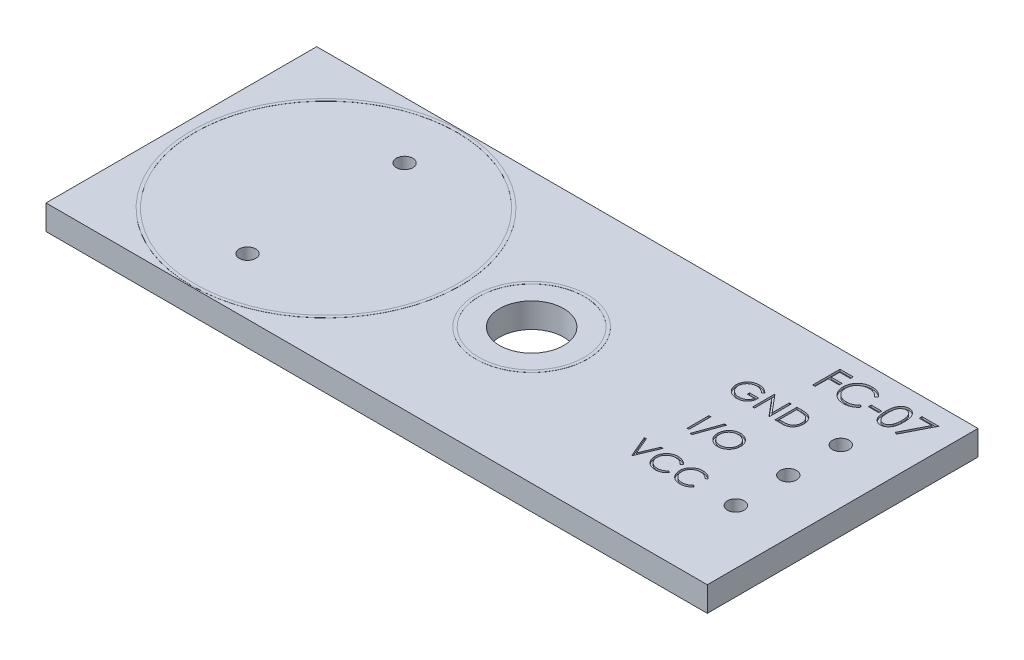
from build123d import *

# Parameters (mm, degrees)
SKETCH1_W           = 32
SKETCH1_H           = 13.1
BOSS_EXTRUDE1_DEPTH = 1.2
CUT_EXTRUDE1_REACH  = 3.2
SKETCH2_R           = 1.55
CUT_EXTRUDE2_REACH  = 3.2
SKETCH4_R           = 0.4
CUT_EXTRUDE3_REACH  = 3.2
SKETCH5_R           = 0.4
SKETCH6_W           = 0.094978632
SKETCH6_H           = 1.058333333
CUT_EXTRUDE4_DEPTH  = 0.1
SKETCH7_W           = 0.508814102
SKETCH7_H           = 0.13568376
CUT_EXTRUDE5_DEPTH  = 0.1
SKETCH8_R           = 6.5
SKETCH8_R_2         = 6.35
SKETCH8_R_3         = 2.7
SKETCH8_R_4         = 2.55
BOSS_EXTRUDE2_DEPTH = 0.005


with BuildPart() as part:
    # Sketch1 → Boss-Extrude1 (new body)
    with BuildSketch(Plane(origin=(0, 0, 0), x_dir=(1, 0, 0), z_dir=(0, 1, 0))):
        Rectangle(SKETCH1_W, SKETCH1_H)
    extrude(amount=BOSS_EXTRUDE1_DEPTH)

    # Sketch2 → Cut-Extrude1 (cut, up to next)
    with BuildSketch(Plane(origin=(0, 1.2, 0), x_dir=(1, 0, 0), z_dir=(0, 1, 0)), mode=Mode.PRIVATE) as cut_extrude1_sk1:
        with Locations((0.95, 0)):
            Circle(SKETCH2_R)
    cut_extrude1_tool1 = extrude(cut_extrude1_sk1.sketch, amount=-CUT_EXTRUDE1_REACH, mode=Mode.PRIVATE) & part.part
    add(cut_extrude1_tool1.solids().sort_by_distance((0.95, 1.2, 0))[0], mode=Mode.SUBTRACT)

    # Sketch4 → Cut-Extrude2 (cut, up to next)
    with BuildSketch(Plane(origin=(0, 1.2, 0), x_dir=(1, 0, 0), z_dir=(0, 1, 0)), mode=Mode.PRIVATE) as cut_extrude2_sk1:
        with Locations((13.37, 0)):
            Circle(SKETCH4_R)
    cut_extrude2_tool1 = extrude(cut_extrude2_sk1.sketch, amount=-CUT_EXTRUDE2_REACH, mode=Mode.PRIVATE) & part.part
    add(cut_extrude2_tool1.solids().sort_by_distance((13.37, 1.2, 0))[0], mode=Mode.SUBTRACT)
    # Sketch4 → Cut-Extrude2 (cut, up to next)
    with BuildSketch(Plane(origin=(0, 1.2, 0), x_dir=(1, 0, 0), z_dir=(0, 1, 0)), mode=Mode.PRIVATE) as cut_extrude2_sk2:
        with Locations((13.37, 2.54)):
            Circle(SKETCH4_R)
    cut_extrude2_tool2 = extrude(cut_extrude2_sk2.sketch, amount=-CUT_EXTRUDE2_REACH, mode=Mode.PRIVATE) & part.part
    add(cut_extrude2_tool2.solids().sort_by_distance((13.37, 1.2, -2.54))[0], mode=Mode.SUBTRACT)
    # Sketch4 → Cut-Extrude2 (cut, up to next)
    with BuildSketch(Plane(origin=(0, 1.2, 0), x_dir=(1, 0, 0), z_dir=(0, 1, 0)), mode=Mode.PRIVATE) as cut_extrude2_sk3:
        with Locations((13.37, -2.54)):
            Circle(SKETCH4_R)
    cut_extrude2_tool3 = extrude(cut_extrude2_sk3.sketch, amount=-CUT_EXTRUDE2_REACH, mode=Mode.PRIVATE) & part.part
    add(cut_extrude2_tool3.solids().sort_by_distance((13.37, 1.2, 2.54))[0], mode=Mode.SUBTRACT)

    # Sketch5 → Cut-Extrude3 (cut, up to next)
    with BuildSketch(Plane(origin=(0, 1.2, 0), x_dir=(1, 0, 0), z_dir=(0, 1, 0)), mode=Mode.PRIVATE) as cut_extrude3_sk1:
        with Locations((-9, -3.8)):
            Circle(SKETCH5_R)
    cut_extrude3_tool1 = extrude(cut_extrude3_sk1.sketch, amount=-CUT_EXTRUDE3_REACH, mode=Mode.PRIVATE) & part.part
    add(cut_extrude3_tool1.solids().sort_by_distance((-9, 1.2, 3.8))[0], mode=Mode.SUBTRACT)
    # Sketch5 → Cut-Extrude3 (cut, up to next)
    with BuildSketch(Plane(origin=(0, 1.2, 0), x_dir=(1, 0, 0), z_dir=(0, 1, 0)), mode=Mode.PRIVATE) as cut_extrude3_sk2:
        with Locations((-9, 3.8)):
            Circle(SKETCH5_R)
    cut_extrude3_tool2 = extrude(cut_extrude3_sk2.sketch, amount=-CUT_EXTRUDE3_REACH, mode=Mode.PRIVATE) & part.part
    add(cut_extrude3_tool2.solids().sort_by_distance((-9, 1.2, -3.8))[0], mode=Mode.SUBTRACT)

    # Sketch6 → Cut-Extrude4 (cut)
    with BuildSketch(Plane(origin=(0, 1.2, 0), x_dir=(1, 0, 0), z_dir=(0, 1, 0))):
        with BuildLine():
            Line((9.359822658, 2.876299306), (9.278412401, 2.799129167))
            add(Edge.make_bspline(
                [(9.278412401, 2.799129167), (9.263680738, 2.812987547), (9.234568695, 2.840373846), (9.187106907, 2.875906933), (9.137587904, 2.906346444), (9.086270077, 2.93111333), (9.034424276, 2.95087476), (8.98273867, 2.964943983), (8.931743422, 2.973916393), (8.897826192, 2.974989353), (8.88111339, 2.975518056)],
                knots=[0, 0, 0, 0, 6.0638e-05, 0.00011983, 0.000177497, 0.000234768, 0.000290524, 0.000343703, 0.000395286, 0.000445395, 0.000445395, 0.000445395, 0.000445395], degree=3))
            add(Edge.make_bspline(
                [(8.88111339, 2.975518056), (8.87085823, 2.97539299), (8.850374509, 2.975143181), (8.81994835, 2.971954811), (8.789841295, 2.967369245), (8.760110179, 2.960734439), (8.730697195, 2.952325509), (8.70170464, 2.941807048), (8.67307843, 2.929543914), (8.64508821, 2.915373595), (8.617952391, 2.89980707), (8.592323539, 2.882556678), (8.568038297, 2.864175306), (8.54555312, 2.844202748), (8.524738671, 2.822819919), (8.505099521, 2.800424586), (8.487326386, 2.776404889), (8.471272629, 2.751202759), (8.456951378, 2.725260835), (8.444309237, 2.698828812), (8.433696546, 2.671994361), (8.425299592, 2.644723809), (8.418371847, 2.617228131), (8.413498189, 2.589316941), (8.410750537, 2.560960356), (8.410275261, 2.541971661), (8.410036333, 2.532425775)],
                knots=[0, 0, 0, 0, 3.0753e-05, 6.1425e-05, 9.168e-05, 0.00012208, 0.000152744, 0.000183391, 0.000214542, 0.000246114, 0.00027746, 0.00030833, 0.000338732, 0.000368769, 0.000398452, 0.000428209, 0.000458059, 0.000487994, 0.000517791, 0.000546904, 0.00057584, 0.000604271, 0.000632449, 0.000660855, 0.000689186, 0.000717826, 0.000717826, 0.000717826, 0.000717826], degree=3))
            add(Edge.make_bspline(
                [(8.410036333, 2.532425775), (8.410264848, 2.522667695), (8.410721253, 2.50317818), (8.41364235, 2.474090925), (8.419063508, 2.445435672), (8.426310887, 2.41711826), (8.435376515, 2.389090192), (8.446677297, 2.361472981), (8.460062371, 2.334267649), (8.475555329, 2.307719321), (8.492544967, 2.281858788), (8.511577755, 2.257499123), (8.531795122, 2.234315945), (8.553933611, 2.212823988), (8.57728333, 2.192448382), (8.602541899, 2.173750498), (8.629212643, 2.156370178), (8.657336252, 2.140526468), (8.68660757, 2.126372459), (8.716620921, 2.113786185), (8.747472189, 2.103420767), (8.778999241, 2.094972816), (8.811164492, 2.088048202), (8.844131213, 2.083593381), (8.877657008, 2.080360677), (8.900256547, 2.080124315), (8.911642236, 2.080005236)],
                knots=[0, 0, 0, 0, 2.9276e-05, 5.8472e-05, 8.7579e-05, 0.000116683, 0.000146115, 0.000175878, 0.000206124, 0.000236996, 0.000268043, 0.000298872, 0.000329665, 0.000360248, 0.000391361, 0.000422569, 0.00045444, 0.000486811, 0.000519334, 0.000551934, 0.000584383, 0.000616885, 0.000649817, 0.000683007, 0.000716635, 0.000750778, 0.000750778, 0.000750778, 0.000750778], degree=3))
            add(Edge.make_bspline(
                [(8.911642236, 2.080005236), (8.925363784, 2.080292067), (8.952308272, 2.080855307), (8.991916077, 2.085239918), (9.02995653, 2.092087877), (9.066322739, 2.102116613), (9.101056943, 2.114908438), (9.134286475, 2.130328472), (9.165749715, 2.148968159), (9.195541246, 2.170005971), (9.22298449, 2.19344498), (9.247735618, 2.21873747), (9.269399849, 2.245760671), (9.28830008, 2.274355421), (9.303935792, 2.304758406), (9.316769685, 2.336820633), (9.326607132, 2.370556524), (9.330645422, 2.393867565), (9.332685906, 2.405646261)],
                knots=[0, 0, 0, 0, 4.1156e-05, 8.0816e-05, 0.000119405, 0.000157002, 0.000193826, 0.000230341, 0.000266738, 0.000303385, 0.000339626, 0.000374858, 0.000409391, 0.000443378, 0.000477514, 0.000511764, 0.000546856, 0.000582697, 0.000582697, 0.000582697, 0.000582697], degree=3))
            Line((9.332685906, 2.405646261), (8.979908128, 2.405646261))
            Line((8.979908128, 2.405646261), (8.979908128, 2.51419327))
            Line((8.979908128, 2.51419327), (9.427664538, 2.51419327))
            add(Edge.make_bspline(
                [(9.427664538, 2.51419327), (9.427148722, 2.49396172), (9.426139177, 2.454364921), (9.419057743, 2.396619149), (9.40762275, 2.342078184), (9.392001655, 2.290684589), (9.371779845, 2.242511193), (9.347174342, 2.197509086), (9.317791343, 2.155968994), (9.284677472, 2.117551796), (9.247514866, 2.0832832), (9.207307688, 2.053164262), (9.163989509, 2.027793709), (9.117601305, 2.007152985), (9.068294936, 1.991043944), (9.015956307, 1.979622539), (8.960656394, 1.972779669), (8.922756971, 1.971905371), (8.903374007, 1.971458227)],
                knots=[0, 0, 0, 0, 6.0687e-05, 0.000118775, 0.000174243, 0.000227691, 0.000279665, 0.000330713, 0.000381237, 0.000432035, 0.000482592, 0.000532583, 0.00058247, 0.000632862, 0.00068462, 0.000737808, 0.000793345, 0.000851482, 0.000851482, 0.000851482, 0.000851482], degree=3))
            add(Edge.make_bspline(
                [(8.903374007, 1.971458227), (8.891426894, 1.971630318), (8.867863338, 1.971969738), (8.833062034, 1.974381936), (8.799220277, 1.978095348), (8.766342998, 1.983703041), (8.734309261, 1.990571519), (8.703279053, 1.999366789), (8.67313417, 2.009547562), (8.643828017, 2.021127445), (8.615626594, 2.034544588), (8.58840429, 2.049454884), (8.562010629, 2.065781448), (8.536625395, 2.083806632), (8.512116324, 2.103395614), (8.488641449, 2.124587656), (8.466069353, 2.147317971), (8.451929879, 2.163458767), (8.444805297, 2.171591774)],
                knots=[0, 0, 0, 0, 3.5839e-05, 7.0686e-05, 0.00010461, 0.00013793, 0.000170699, 0.000202849, 0.000234627, 0.000266122, 0.000297322, 0.000328252, 0.000359197, 0.000390373, 0.000421596, 0.00045327, 0.000485201, 0.000517632, 0.000517632, 0.000517632, 0.000517632], degree=3))
            add(Edge.make_bspline(
                [(8.444805297, 2.171591774), (8.434468122, 2.184494567), (8.413965359, 2.210085979), (8.387574107, 2.251088819), (8.36507654, 2.293543668), (8.34682246, 2.33756871), (8.332568801, 2.383122767), (8.322346434, 2.430147629), (8.316357087, 2.478703851), (8.315494232, 2.511562157), (8.3150577, 2.528185658)],
                knots=[0, 0, 0, 0, 4.9572e-05, 9.8322e-05, 0.000146023, 0.000193545, 0.000241086, 0.000289032, 0.000337732, 0.000387599, 0.000387599, 0.000387599, 0.000387599], degree=3))
            add(Edge.make_bspline(
                [(8.3150577, 2.528185658), (8.315218639, 2.540633548), (8.315538471, 2.565371125), (8.319416663, 2.602097501), (8.324980901, 2.638171758), (8.333159415, 2.673564407), (8.343469476, 2.708299086), (8.35633684, 2.742391923), (8.371318273, 2.775863036), (8.38873103, 2.808482039), (8.40810895, 2.839816088), (8.429139612, 2.869739043), (8.452121653, 2.897705974), (8.476679763, 2.924071068), (8.503106949, 2.9485031), (8.531155631, 2.971228272), (8.560847428, 2.992277066), (8.592275749, 3.011317944), (8.624971501, 3.028421706), (8.658856311, 3.043416539), (8.693919835, 3.055809113), (8.729899382, 3.066324042), (8.767067293, 3.07409981), (8.805153848, 3.079738836), (8.844357573, 3.083597398), (8.870857039, 3.083907718), (8.884293478, 3.084065065)],
                knots=[0, 0, 0, 0, 3.7328e-05, 7.4182e-05, 0.000110674, 0.000146778, 0.000183065, 0.000219293, 0.000256017, 0.000293005, 0.000330131, 0.000366483, 0.000402641, 0.000438639, 0.000474493, 0.000510518, 0.00054687, 0.000583593, 0.00062067, 0.000657501, 0.000694651, 0.000732159, 0.000769873, 0.000808461, 0.000847636, 0.000887931, 0.000887931, 0.000887931, 0.000887931], degree=3))
            add(Edge.make_bspline(
                [(8.884293478, 3.084065065), (8.895251232, 3.083889837), (8.916979172, 3.083542382), (8.949311477, 3.081134024), (8.981144031, 3.077316803), (9.012524035, 3.072107751), (9.043344627, 3.065012778), (9.073693607, 3.05652244), (9.103614969, 3.046637055), (9.133014939, 3.034847571), (9.162091201, 3.021466117), (9.191005424, 3.006403487), (9.219658815, 2.989402117), (9.248101064, 2.970411524), (9.276511526, 2.949757871), (9.304440835, 2.926850451), (9.332563154, 2.902592618), (9.350646083, 2.885150624), (9.359822658, 2.876299306)],
                knots=[0, 0, 0, 0, 3.2872e-05, 6.5181e-05, 9.721e-05, 0.000129031, 0.000160558, 0.000192039, 0.000223549, 0.000255044, 0.000287012, 0.000319538, 0.000352806, 0.00038691, 0.000422106, 0.00045813, 0.000495246, 0.000533487, 0.000533487, 0.000533487, 0.000533487], degree=3))
        make_face()
        Polygon((9.644758555, 1.998594979), (9.644758555, 3.056928312), (9.664687108, 3.056928312), (10.363882487, 2.223957225), (10.363882487, 3.056928312), (10.458861119, 3.056928312), (10.458861119, 1.998594979), (10.43723652, 1.998594979), (9.739737188, 2.829658013), (9.739737188, 1.998594979), align=None)
        with BuildLine():
            Line((10.730228641, 1.998594979), (10.730228641, 3.056928312))
            Line((10.730228641, 3.056928312), (10.943930564, 3.056928312))
            add(Edge.make_bspline(
                [(10.943930564, 3.056928312), (10.962517615, 3.056794488), (10.998427701, 3.056535939), (11.050320036, 3.054896614), (11.098333222, 3.051996639), (11.142309348, 3.047772521), (11.182369143, 3.04258577), (11.218400437, 3.036084457), (11.250589537, 3.028407558), (11.270386249, 3.021862386), (11.279747871, 3.018767255)],
                knots=[0, 0, 0, 0, 5.5761e-05, 0.00010773, 0.000155735, 0.000200036, 0.000240244, 0.000276879, 0.000309839, 0.000339409, 0.000339409, 0.000339409, 0.000339409], degree=3))
            add(Edge.make_bspline(
                [(11.279747871, 3.018767255), (11.291992709, 3.014101303), (11.316204713, 3.004875209), (11.350678295, 2.987471279), (11.38313144, 2.96775208), (11.413738182, 2.945691616), (11.441799384, 2.920665254), (11.468411296, 2.893736088), (11.492485272, 2.863924851), (11.514531352, 2.831849795), (11.534408563, 2.79788877), (11.551686356, 2.762106487), (11.56603554, 2.724684665), (11.577947301, 2.68572737), (11.587335158, 2.645148942), (11.593740171, 2.60290213), (11.597964732, 2.559153899), (11.598389291, 2.529467811), (11.598604709, 2.514405276)],
                knots=[0, 0, 0, 0, 3.929e-05, 7.7689e-05, 0.000115648, 0.000153134, 0.000190689, 0.000228319, 0.000266595, 0.000305467, 0.000344991, 0.000384532, 0.000424533, 0.000465106, 0.00050666, 0.000549358, 0.000593216, 0.000638392, 0.000638392, 0.000638392, 0.000638392], degree=3))
            add(Edge.make_bspline(
                [(11.598604709, 2.514405276), (11.598414521, 2.501323901), (11.598039736, 2.475545686), (11.594674443, 2.437554273), (11.589783032, 2.400689931), (11.582210144, 2.365128207), (11.573017003, 2.330557532), (11.561234986, 2.297346353), (11.547738062, 2.265190011), (11.53199917, 2.234523298), (11.514720703, 2.205469516), (11.496178176, 2.178081202), (11.476391366, 2.15274917), (11.455171591, 2.129396709), (11.432793068, 2.108059022), (11.409109282, 2.088557865), (11.384059121, 2.071274812), (11.357754784, 2.05553071), (11.329428907, 2.04179646), (11.298544966, 2.030175957), (11.264971253, 2.020546147), (11.228790175, 2.012511614), (11.189939219, 2.006138239), (11.148380294, 2.001866687), (11.104177251, 1.998978062), (11.073824473, 1.998725153), (11.058201731, 1.998594979)],
                knots=[0, 0, 0, 0, 3.9235e-05, 7.7317e-05, 0.000114346, 0.000150727, 0.000186317, 0.000221585, 0.000256355, 0.000290867, 0.000324899, 0.000357711, 0.000390028, 0.000421245, 0.000452286, 0.000482716, 0.00051318, 0.000543503, 0.000574604, 0.000607482, 0.00064237, 0.0006793, 0.000718615, 0.000760406, 0.000804589, 0.00085145, 0.00085145, 0.00085145, 0.00085145], degree=3))
            Line((11.058201731, 1.998594979), (10.730228641, 1.998594979))
        make_face()
        with BuildLine():
            Line((10.825207273, 2.107141988), (10.94668664, 2.107141988))
            add(Edge.make_bspline(
                [(10.94668664, 2.107141988), (10.9641426, 2.107217007), (10.997716803, 2.107361297), (11.04599434, 2.108627428), (11.090105491, 2.1106963), (11.130056519, 2.113591621), (11.165824867, 2.117422369), (11.197485287, 2.12169347), (11.224933996, 2.127014604), (11.241543611, 2.13183787), (11.249219025, 2.134066734)],
                knots=[0, 0, 0, 0, 5.2367e-05, 0.000100721, 0.000144869, 0.000184837, 0.000220869, 0.00025277, 0.000280668, 0.000304636, 0.000304636, 0.000304636, 0.000304636], degree=3))
            add(Edge.make_bspline(
                [(11.249219025, 2.134066734), (11.258879601, 2.137468991), (11.277970011, 2.144192242), (11.30545072, 2.156456106), (11.331079624, 2.170983113), (11.35530337, 2.187130943), (11.377778335, 2.205469139), (11.398770865, 2.225598938), (11.418238695, 2.247622787), (11.435980688, 2.27151335), (11.451858199, 2.297121931), (11.465607833, 2.324196769), (11.477658177, 2.352441209), (11.487116228, 2.382288978), (11.494529274, 2.413473241), (11.499780024, 2.445996192), (11.503050191, 2.479851755), (11.503431629, 2.502878707), (11.503626077, 2.514617281)],
                knots=[0, 0, 0, 0, 3.072e-05, 6.0706e-05, 9.0132e-05, 0.000119003, 0.000147941, 0.00017703, 0.000206168, 0.000236019, 0.0002662, 0.000296446, 0.000327041, 0.000358217, 0.000390253, 0.00042312, 0.000456979, 0.000492188, 0.000492188, 0.000492188, 0.000492188], degree=3))
            add(Edge.make_bspline(
                [(11.503626077, 2.514617281), (11.503470868, 2.526994786), (11.50316596, 2.551310504), (11.49933349, 2.586988643), (11.493732924, 2.62130303), (11.485634048, 2.65425596), (11.47531352, 2.685911724), (11.462433712, 2.716095243), (11.447717853, 2.745125286), (11.430208987, 2.772331821), (11.41103332, 2.798062356), (11.389752389, 2.821634438), (11.366704297, 2.843101762), (11.342140426, 2.862798649), (11.315368493, 2.879932665), (11.287019163, 2.895259352), (11.256676543, 2.908266539), (11.235566514, 2.915184671), (11.22483835, 2.918700481)],
                knots=[0, 0, 0, 0, 3.7116e-05, 7.2915e-05, 0.000107525, 0.000141359, 0.000174612, 0.000207294, 0.000239722, 0.000272128, 0.000304226, 0.0003359, 0.000367249, 0.000398637, 0.000430215, 0.000462465, 0.00049523, 0.000529088, 0.000529088, 0.000529088, 0.000529088], degree=3))
            add(Edge.make_bspline(
                [(11.22483835, 2.918700481), (11.215963122, 2.921154734), (11.197091953, 2.92637315), (11.166297639, 2.932065584), (11.131640201, 2.937086468), (11.092965767, 2.941337352), (11.050318424, 2.944387566), (11.00366537, 2.946676987), (10.952986442, 2.948221135), (10.917855057, 2.948326578), (10.899621336, 2.948381304)],
                knots=[0, 0, 0, 0, 2.7614e-05, 5.8714e-05, 9.3854e-05, 0.000132671, 0.000175403, 0.000222102, 0.000272793, 0.000327492, 0.000327492, 0.000327492, 0.000327492], degree=3))
            Line((10.899621336, 2.948381304), (10.825207273, 2.948381304))
            Line((10.825207273, 2.948381304), (10.825207273, 2.107141988))
        make_face(mode=Mode.SUBTRACT)
        with Locations((9.000260692, 0.046631621)):
            Rectangle(SKETCH6_W, SKETCH6_H)
        Polygon((9.780442316, 0.60293504), (9.337774047, -0.631787182), (9.237707273, -0.631787182), (9.680375542, 0.60293504), align=None)
        with BuildLine():
            add(Edge.make_bspline(
                [(10.452076931, 0.60293504), (10.471673668, 0.602438688), (10.510163276, 0.601463812), (10.566731162, 0.594001321), (10.620734917, 0.581091048), (10.672614459, 0.563896765), (10.72174924, 0.540959844), (10.768509095, 0.513236002), (10.812782769, 0.480434787), (10.85397352, 0.442809759), (10.891667407, 0.401872381), (10.924876663, 0.358185013), (10.9527085, 0.312011804), (10.975564202, 0.263491505), (10.993494972, 0.212733848), (11.005868112, 0.159468233), (11.01377179, 0.104039781), (11.014695799, 0.066234039), (11.015164538, 0.047055633)],
                knots=[0, 0, 0, 0, 5.8781e-05, 0.00011545, 0.000170782, 0.000225153, 0.000279125, 0.000333119, 0.000387987, 0.000444118, 0.000500236, 0.000554722, 0.00060846, 0.000661664, 0.000715372, 0.000769623, 0.000825481, 0.00088299, 0.00088299, 0.00088299, 0.00088299], degree=3))
            add(Edge.make_bspline(
                [(11.015164538, 0.047055633), (11.014695868, 0.028018501), (11.013772065, -0.009505893), (11.005859125, -0.064582601), (10.993449108, -0.117526693), (10.975730714, -0.168249783), (10.952983962, -0.21680538), (10.924966803, -0.263065721), (10.89196458, -0.307045971), (10.854406794, -0.348264325), (10.813464098, -0.386061179), (10.769549231, -0.418996172), (10.723649823, -0.447336562), (10.675175221, -0.469949721), (10.624768305, -0.488023611), (10.571977935, -0.50034643), (10.517051477, -0.508295131), (10.479595245, -0.509207873), (10.460557166, -0.509671797)],
                knots=[0, 0, 0, 0, 5.7086e-05, 0.000112524, 0.000166569, 0.000220006, 0.000273402, 0.00032714, 0.000381965, 0.000438096, 0.000494214, 0.00054887, 0.000602537, 0.000655741, 0.000709049, 0.000762887, 0.000818115, 0.000875201, 0.000875201, 0.000875201, 0.000875201], degree=3))
            add(Edge.make_bspline(
                [(10.460557166, -0.509671797), (10.44137886, -0.509203292), (10.403573314, -0.508279744), (10.34807521, -0.500362986), (10.294772178, -0.487983115), (10.243816648, -0.470290976), (10.195180205, -0.447425766), (10.148767728, -0.419544918), (10.10476551, -0.386462283), (10.063538363, -0.348916676), (10.025816581, -0.308043373), (9.992929818, -0.264248253), (9.9650427, -0.218390532), (9.942254264, -0.170342947), (9.924212868, -0.120337773), (9.911904506, -0.068041447), (9.903941016, -0.01375212), (9.903023336, 0.023211804), (9.9025577, 0.041967492)],
                knots=[0, 0, 0, 0, 5.751e-05, 0.000113367, 0.000167825, 0.000221463, 0.000274858, 0.000328778, 0.000383603, 0.000439735, 0.000495852, 0.000550211, 0.000603768, 0.000656588, 0.000709497, 0.000762923, 0.000817521, 0.00087376, 0.00087376, 0.00087376, 0.00087376], degree=3))
            add(Edge.make_bspline(
                [(9.9025577, 0.041967492), (9.902719364, 0.054556418), (9.903040652, 0.079575456), (9.906908616, 0.116727975), (9.912521321, 0.153283008), (9.920565232, 0.189136604), (9.93108557, 0.224200997), (9.943498921, 0.258718013), (9.958660255, 0.292337853), (9.975799404, 0.325219784), (9.994928569, 0.356851222), (10.016057665, 0.386750524), (10.03844455, 0.415168588), (10.062986814, 0.441368991), (10.088875597, 0.46611393), (10.116530868, 0.489023133), (10.14578388, 0.510303177), (10.176760505, 0.529480281), (10.208697459, 0.54682459), (10.241619723, 0.561708341), (10.275080162, 0.574482745), (10.309235496, 0.584836518), (10.343995025, 0.593010491), (10.379434612, 0.598576524), (10.415526024, 0.602454354), (10.439840876, 0.602774122), (10.452076931, 0.60293504)],
                knots=[0, 0, 0, 0, 3.7752e-05, 7.5028e-05, 0.000111939, 0.000148663, 0.000185154, 0.000221705, 0.000258622, 0.0002957, 0.000332895, 0.000369421, 0.000405477, 0.000441331, 0.000477021, 0.000512852, 0.000548983, 0.000585456, 0.000622071, 0.000657934, 0.000693765, 0.000729444, 0.000764928, 0.000800792, 0.000837013, 0.000873706, 0.000873706, 0.000873706, 0.000873706], degree=3))
        make_face()
        with BuildLine():
            add(Edge.make_bspline(
                [(10.456741061, 0.494388032), (10.446697588, 0.494265601), (10.426706659, 0.494021909), (10.396987288, 0.490811919), (10.367658774, 0.486236928), (10.338715062, 0.479711088), (10.310277256, 0.470819862), (10.28208028, 0.460587016), (10.254381261, 0.448122544), (10.227271642, 0.434039845), (10.200990179, 0.418452433), (10.1761911, 0.401225256), (10.152810206, 0.382762312), (10.130904742, 0.363020514), (10.11053903, 0.341899325), (10.091312228, 0.319718945), (10.073994997, 0.295845397), (10.058124358, 0.27092606), (10.043922178, 0.244993391), (10.03129313, 0.218320409), (10.020962585, 0.190689537), (10.012537533, 0.162400542), (10.00555259, 0.133498227), (10.00112757, 0.103763339), (9.997882309, 0.073345293), (9.997652546, 0.052788875), (9.997536333, 0.042391504)],
                knots=[0, 0, 0, 0, 3.0117e-05, 5.9946e-05, 8.9572e-05, 0.000119144, 0.000148853, 0.000178903, 0.000209082, 0.0002399, 0.000270514, 0.000300683, 0.000330416, 0.000359836, 0.000389072, 0.000418391, 0.00044782, 0.000477462, 0.00050697, 0.000536467, 0.00056592, 0.000595365, 0.000624985, 0.00065503, 0.000685492, 0.000716668, 0.000716668, 0.000716668, 0.000716668], degree=3))
            add(Edge.make_bspline(
                [(9.997536333, 0.042391504), (9.997921827, 0.027102452), (9.998680213, -0.002975845), (10.005319764, -0.047053355), (10.015546885, -0.089413384), (10.030622803, -0.129824152), (10.049476441, -0.168633018), (10.072767905, -0.205495707), (10.100362914, -0.240422181), (10.13170879, -0.273168608), (10.165975418, -0.303057696), (10.202361744, -0.329293298), (10.240477954, -0.35149116), (10.280423446, -0.369575074), (10.321984964, -0.383904828), (10.365430318, -0.393725748), (10.4104701, -0.400189278), (10.441171036, -0.400809993), (10.456741061, -0.401124789)],
                knots=[0, 0, 0, 0, 4.5842e-05, 9.0186e-05, 0.00013343, 0.000176357, 0.000219309, 0.000262659, 0.000306895, 0.00035263, 0.000398461, 0.000443118, 0.000487007, 0.000530556, 0.00057447, 0.000618645, 0.000664009, 0.00071069, 0.00071069, 0.00071069, 0.00071069], degree=3))
            add(Edge.make_bspline(
                [(10.456741061, -0.401124789), (10.467206315, -0.400981005), (10.487962057, -0.400695839), (10.518833798, -0.397823621), (10.549149367, -0.393217793), (10.578866242, -0.386586381), (10.607950697, -0.378286868), (10.636524125, -0.368426913), (10.66428218, -0.356125691), (10.691575035, -0.342534287), (10.717699613, -0.327040239), (10.742638643, -0.310397751), (10.765763523, -0.291962002), (10.787652599, -0.27251352), (10.808101924, -0.251660166), (10.826973212, -0.229429052), (10.844202919, -0.205679853), (10.860067531, -0.180798314), (10.874219946, -0.154794685), (10.886550769, -0.128024996), (10.897011975, -0.100555166), (10.905457023, -0.072345571), (10.91207477, -0.043449791), (10.916634651, -0.013829134), (10.919824298, 0.016457143), (10.920064714, 0.036941595), (10.920185906, 0.047267639)],
                knots=[0, 0, 0, 0, 3.1388e-05, 6.2252e-05, 9.2926e-05, 0.000123326, 0.000153524, 0.00018363, 0.000213918, 0.000244542, 0.000275048, 0.000304978, 0.000334413, 0.000363692, 0.000392777, 0.000421958, 0.00045109, 0.000480732, 0.000510427, 0.000539834, 0.000569089, 0.000598533, 0.000628106, 0.000657941, 0.000688403, 0.000719368, 0.000719368, 0.000719368, 0.000719368], degree=3))
            add(Edge.make_bspline(
                [(10.920185906, 0.047267639), (10.920064617, 0.057523042), (10.919824018, 0.077866522), (10.916636174, 0.107941579), (10.912069953, 0.137349097), (10.905489324, 0.165973628), (10.897007492, 0.193822468), (10.886548942, 0.220869461), (10.874216244, 0.247215367), (10.860062329, 0.272795071), (10.844152306, 0.297340766), (10.826767142, 0.320806257), (10.807606668, 0.342750872), (10.787218322, 0.363716363), (10.76509284, 0.383255582), (10.741330446, 0.401375011), (10.71621962, 0.418511929), (10.689632099, 0.433971325), (10.662192856, 0.44824801), (10.634036968, 0.460479623), (10.605483407, 0.470873097), (10.576604783, 0.479737989), (10.547158025, 0.486211369), (10.517342106, 0.490816042), (10.487198275, 0.494020792), (10.466925682, 0.49426523), (10.456741061, 0.494388032)],
                knots=[0, 0, 0, 0, 3.0753e-05, 6.1003e-05, 9.063e-05, 0.000119995, 0.000149034, 0.000177893, 0.000206916, 0.000236238, 0.000265524, 0.000294611, 0.000323769, 0.000352853, 0.000382291, 0.000412228, 0.000442452, 0.000473431, 0.000504437, 0.000535198, 0.000565447, 0.000595561, 0.000625754, 0.000655799, 0.00068605, 0.000716591, 0.000716591, 0.000716591, 0.000716591], degree=3))
        make_face(mode=Mode.SUBTRACT)
        Polygon((8.308273512, -1.905331736), (8.410036333, -1.905331736), (8.762814111, -2.739362853), (9.115591888, -1.905331736), (9.217354709, -1.905331736), (8.769598299, -2.963665069), (8.756029923, -2.963665069), align=None)
        with BuildLine():
            Line((10.384235051, -2.099529119), (10.301128747, -2.163130881))
            add(Edge.make_bspline(
                [(10.301128747, -2.163130881), (10.2952003, -2.156065457), (10.283423334, -2.142029866), (10.264476385, -2.122320813), (10.244730412, -2.103855841), (10.224192963, -2.086546987), (10.202494372, -2.070999537), (10.180160274, -2.056403275), (10.156817055, -2.043319935), (10.124537364, -2.027456127), (10.082310515, -2.010901933), (10.029153504, -1.99702167), (9.973663243, -1.988185743), (9.935805874, -1.987228755), (9.916550088, -1.986741993)],
                knots=[0, 0, 0, 0, 2.7663e-05, 5.4954e-05, 8.1953e-05, 0.000108744, 0.00013546, 0.000161981, 0.000188751, 0.000215679, 0.000269851, 0.000324464, 0.000380234, 0.000437965, 0.000437965, 0.000437965, 0.000437965], degree=3))
            add(Edge.make_bspline(
                [(9.916550088, -1.986741993), (9.905941567, -1.986864143), (9.884822981, -1.987107311), (9.853481657, -1.990315308), (9.822725568, -1.994824174), (9.792574719, -2.00151445), (9.763067492, -2.009972837), (9.734010979, -2.020080046), (9.70582587, -2.032584962), (9.678122259, -2.046406269), (9.651579498, -2.062017425), (9.626465234, -2.07904551), (9.602871062, -2.097299975), (9.58077832, -2.116849238), (9.560164421, -2.137605259), (9.541178735, -2.159789239), (9.523886956, -2.183330253), (9.507946331, -2.207917879), (9.4936701, -2.233480497), (9.481717018, -2.26011272), (9.471132135, -2.287358485), (9.462756412, -2.315525621), (9.456126856, -2.344415934), (9.451552539, -2.374106958), (9.448381025, -2.404536666), (9.448139066, -2.425161863), (9.448017102, -2.435558432)],
                knots=[0, 0, 0, 0, 3.1812e-05, 6.3329e-05, 9.4422e-05, 0.000125029, 0.000155897, 0.000186473, 0.000217234, 0.000248333, 0.000279312, 0.000309536, 0.000339305, 0.000368743, 0.000397976, 0.000426996, 0.000456253, 0.000485538, 0.000514861, 0.000543987, 0.000573044, 0.000602489, 0.000632061, 0.000661897, 0.00069257, 0.000723746, 0.000723746, 0.000723746, 0.000723746], degree=3))
            add(Edge.make_bspline(
                [(9.448017102, -2.435558432), (9.448398652, -2.451200998), (9.449147775, -2.481913101), (9.455814771, -2.5268985), (9.465946073, -2.569994037), (9.481130307, -2.610930323), (9.499853448, -2.650212136), (9.523511919, -2.687174837), (9.550912634, -2.722376988), (9.582443232, -2.754986641), (9.617037372, -2.784775316), (9.654154002, -2.811007039), (9.693700679, -2.832873682), (9.735240756, -2.851069742), (9.77909389, -2.865056895), (9.825181223, -2.874903666), (9.873402517, -2.881326897), (9.906352788, -2.881941845), (9.92312227, -2.882254813)],
                knots=[0, 0, 0, 0, 4.6901e-05, 9.2084e-05, 0.000136152, 0.000179478, 0.00022281, 0.000266453, 0.000310856, 0.000356437, 0.00040229, 0.000447638, 0.000492529, 0.000537627, 0.000583487, 0.000630351, 0.000678868, 0.000729149, 0.000729149, 0.000729149, 0.000729149], degree=3))
            add(Edge.make_bspline(
                [(9.92312227, -2.882254813), (9.94159856, -2.881744158), (9.977964317, -2.880739067), (10.031294649, -2.872224247), (10.082347368, -2.858418162), (10.131125222, -2.839096647), (10.177490698, -2.813979287), (10.221516355, -2.783530167), (10.263239354, -2.747459647), (10.288328289, -2.719917844), (10.301128747, -2.705865924)],
                knots=[0, 0, 0, 0, 5.5402e-05, 0.000109045, 0.000161555, 0.000213797, 0.000266063, 0.000319402, 0.000374108, 0.000431094, 0.000431094, 0.000431094, 0.000431094], degree=3))
            Line((10.301128747, -2.705865924), (10.384235051, -2.768831669))
            add(Edge.make_bspline(
                [(10.384235051, -2.768831669), (10.377546956, -2.777461154), (10.364202801, -2.794678787), (10.342595258, -2.818951423), (10.319832837, -2.841782406), (10.295746468, -2.862987663), (10.270613231, -2.882991513), (10.243981841, -2.901225638), (10.216202395, -2.917944548), (10.187369017, -2.933253166), (10.157512341, -2.946835286), (10.126668143, -2.958462973), (10.094969374, -2.968479308), (10.062414585, -2.976719775), (10.028936249, -2.983151746), (9.994655177, -2.987451504), (9.959497381, -2.990397274), (9.935778189, -2.990665763), (9.923758288, -2.990801822)],
                knots=[0, 0, 0, 0, 3.2746e-05, 6.5335e-05, 9.7416e-05, 0.000129406, 0.000161556, 0.000193723, 0.000226155, 0.000258779, 0.000291607, 0.000324485, 0.000357609, 0.000391288, 0.000425175, 0.000459808, 0.000494897, 0.000530948, 0.000530948, 0.000530948, 0.000530948], degree=3))
            add(Edge.make_bspline(
                [(9.923758288, -2.990801822), (9.91237556, -2.9907226), (9.889867625, -2.990565949), (9.856636336, -2.988028318), (9.824284725, -2.984566135), (9.792905255, -2.979353048), (9.762326686, -2.973201307), (9.732826223, -2.964954999), (9.704113577, -2.955717512), (9.676304102, -2.944860528), (9.649374145, -2.932609207), (9.623410564, -2.918762711), (9.5984253, -2.903437481), (9.574172709, -2.886971323), (9.551011058, -2.868835329), (9.528739635, -2.849281371), (9.507233553, -2.828375353), (9.493927979, -2.813300195), (9.487238189, -2.805720692)],
                knots=[0, 0, 0, 0, 3.4139e-05, 6.7505e-05, 9.9931e-05, 0.000131718, 0.000162902, 0.000193452, 0.000223555, 0.000253358, 0.000282958, 0.000312265, 0.000341571, 0.000370855, 0.000400159, 0.000429756, 0.00045974, 0.000490059, 0.000490059, 0.000490059, 0.000490059], degree=3))
            add(Edge.make_bspline(
                [(9.487238189, -2.805720692), (9.476523126, -2.792554666), (9.45522236, -2.766381565), (9.42797007, -2.723961756), (9.404642119, -2.67967256), (9.385780828, -2.633281296), (9.371035907, -2.584892062), (9.360821117, -2.534480466), (9.35418337, -2.482093588), (9.353424306, -2.446461988), (9.35303847, -2.428350232)],
                knots=[0, 0, 0, 0, 5.0892e-05, 0.00010117, 0.000150956, 0.000200876, 0.000251176, 0.000302484, 0.000355024, 0.000409339, 0.000409339, 0.000409339, 0.000409339], degree=3))
            add(Edge.make_bspline(
                [(9.35303847, -2.428350232), (9.353508731, -2.409313702), (9.35443394, -2.371860518), (9.362294573, -2.316895537), (9.37493978, -2.264235471), (9.392900268, -2.213978625), (9.415671172, -2.165860659), (9.443800648, -2.120249152), (9.476961903, -2.076852405), (9.514894858, -2.036328897), (9.5564926, -1.999275331), (9.601039003, -1.966676788), (9.648446878, -1.93954792), (9.698193942, -1.916870509), (9.750652708, -1.899439922), (9.80571125, -1.887237887), (9.863266113, -1.879642949), (9.902534037, -1.878682827), (9.922486253, -1.878194984)],
                knots=[0, 0, 0, 0, 5.7086e-05, 0.000112314, 0.000166202, 0.00021931, 0.000272131, 0.000325617, 0.000379766, 0.000435716, 0.00049188, 0.000546668, 0.000600996, 0.000655458, 0.000710433, 0.000766495, 0.000824426, 0.000884266, 0.000884266, 0.000884266, 0.000884266], degree=3))
            add(Edge.make_bspline(
                [(9.922486253, -1.878194984), (9.934646343, -1.878340773), (9.958716017, -1.878629349), (9.994322177, -1.881443349), (10.028987833, -1.886134368), (10.062736868, -1.892519465), (10.095733468, -1.90044406), (10.127725446, -1.910767436), (10.158900525, -1.92257134), (10.18906209, -1.936165923), (10.218065428, -1.951426105), (10.245901505, -1.968182734), (10.272349212, -1.986415037), (10.29759465, -2.005967949), (10.321215504, -2.027255133), (10.343882427, -2.049691072), (10.364825658, -2.073922015), (10.37775341, -2.090977792), (10.384235051, -2.099529119)],
                knots=[0, 0, 0, 0, 3.6475e-05, 7.2198e-05, 0.000107069, 0.000141372, 0.000175206, 0.000208798, 0.000242147, 0.000275169, 0.00030798, 0.000340412, 0.000372579, 0.000404301, 0.000436133, 0.000467914, 0.000499924, 0.000532111, 0.000532111, 0.000532111, 0.000532111], degree=3))
        make_face()
        with BuildLine():
            Line((11.578252145, -2.099529119), (11.495145841, -2.163130881))
            add(Edge.make_bspline(
                [(11.495145841, -2.163130881), (11.489217394, -2.156065457), (11.477440428, -2.142029866), (11.458493479, -2.122320813), (11.438747506, -2.103855841), (11.418210057, -2.086546987), (11.396511466, -2.070999537), (11.374177368, -2.056403275), (11.350834149, -2.043319935), (11.318554458, -2.027456127), (11.276327609, -2.010901933), (11.223170598, -1.99702167), (11.167680337, -1.988185743), (11.129822968, -1.987228755), (11.110567182, -1.986741993)],
                knots=[0, 0, 0, 0, 2.7663e-05, 5.4954e-05, 8.1953e-05, 0.000108744, 0.00013546, 0.000161981, 0.000188751, 0.000215679, 0.000269851, 0.000324464, 0.000380234, 0.000437965, 0.000437965, 0.000437965, 0.000437965], degree=3))
            add(Edge.make_bspline(
                [(11.110567182, -1.986741993), (11.099958661, -1.986864143), (11.078840075, -1.987107311), (11.047498751, -1.990315308), (11.016742662, -1.994824174), (10.986591813, -2.00151445), (10.957084586, -2.009972837), (10.928028073, -2.020080046), (10.899842964, -2.032584962), (10.872139353, -2.046406269), (10.845596592, -2.062017425), (10.820482328, -2.07904551), (10.796888156, -2.097299975), (10.774795414, -2.116849238), (10.754181515, -2.137605259), (10.735195829, -2.159789239), (10.71790405, -2.183330253), (10.701963425, -2.207917879), (10.687687194, -2.233480497), (10.675734112, -2.26011272), (10.665149229, -2.287358485), (10.656773506, -2.315525621), (10.65014395, -2.344415934), (10.645569633, -2.374106958), (10.642398119, -2.404536666), (10.64215616, -2.425161863), (10.642034196, -2.435558432)],
                knots=[0, 0, 0, 0, 3.1812e-05, 6.3329e-05, 9.4422e-05, 0.000125029, 0.000155897, 0.000186473, 0.000217234, 0.000248333, 0.000279312, 0.000309536, 0.000339305, 0.000368743, 0.000397976, 0.000426996, 0.000456253, 0.000485538, 0.000514861, 0.000543987, 0.000573044, 0.000602489, 0.000632061, 0.000661897, 0.00069257, 0.000723746, 0.000723746, 0.000723746, 0.000723746], degree=3))
            add(Edge.make_bspline(
                [(10.642034196, -2.435558432), (10.642415746, -2.451200998), (10.643164869, -2.481913101), (10.649831865, -2.5268985), (10.659963167, -2.569994037), (10.675147401, -2.610930323), (10.693870542, -2.650212136), (10.717529013, -2.687174837), (10.744929728, -2.722376988), (10.776460326, -2.754986641), (10.811054466, -2.784775316), (10.848171096, -2.811007039), (10.887717774, -2.832873682), (10.92925785, -2.851069742), (10.973110984, -2.865056895), (11.019198317, -2.874903666), (11.067419611, -2.881326897), (11.100369882, -2.881941845), (11.117139364, -2.882254813)],
                knots=[0, 0, 0, 0, 4.6901e-05, 9.2084e-05, 0.000136152, 0.000179478, 0.00022281, 0.000266453, 0.000310856, 0.000356437, 0.00040229, 0.000447638, 0.000492529, 0.000537627, 0.000583487, 0.000630351, 0.000678868, 0.000729149, 0.000729149, 0.000729149, 0.000729149], degree=3))
            add(Edge.make_bspline(
                [(11.117139364, -2.882254813), (11.135615654, -2.881744158), (11.171981411, -2.880739067), (11.225311743, -2.872224247), (11.276364462, -2.858418162), (11.325142316, -2.839096647), (11.371507792, -2.813979287), (11.415533449, -2.783530167), (11.457256448, -2.747459647), (11.482345383, -2.719917844), (11.495145841, -2.705865924)],
                knots=[0, 0, 0, 0, 5.5402e-05, 0.000109045, 0.000161555, 0.000213797, 0.000266063, 0.000319402, 0.000374108, 0.000431094, 0.000431094, 0.000431094, 0.000431094], degree=3))
            Line((11.495145841, -2.705865924), (11.578252145, -2.768831669))
            add(Edge.make_bspline(
                [(11.578252145, -2.768831669), (11.57156405, -2.777461154), (11.558219895, -2.794678787), (11.536612352, -2.818951423), (11.513849931, -2.841782406), (11.489763562, -2.862987663), (11.464630325, -2.882991513), (11.437998935, -2.901225638), (11.410219489, -2.917944548), (11.381386111, -2.933253166), (11.351529435, -2.946835286), (11.320685237, -2.958462973), (11.288986468, -2.968479308), (11.256431679, -2.976719775), (11.222953343, -2.983151746), (11.188672271, -2.987451504), (11.153514475, -2.990397274), (11.129795283, -2.990665763), (11.117775382, -2.990801822)],
                knots=[0, 0, 0, 0, 3.2746e-05, 6.5335e-05, 9.7416e-05, 0.000129406, 0.000161556, 0.000193723, 0.000226155, 0.000258779, 0.000291607, 0.000324485, 0.000357609, 0.000391288, 0.000425175, 0.000459808, 0.000494897, 0.000530948, 0.000530948, 0.000530948, 0.000530948], degree=3))
            add(Edge.make_bspline(
                [(11.117775382, -2.990801822), (11.106392654, -2.9907226), (11.083884719, -2.990565949), (11.05065343, -2.988028318), (11.018301819, -2.984566135), (10.986922349, -2.979353048), (10.95634378, -2.973201307), (10.926843318, -2.964954999), (10.898130671, -2.955717512), (10.870321196, -2.944860528), (10.843391239, -2.932609207), (10.817427658, -2.918762711), (10.792442394, -2.903437481), (10.768189803, -2.886971323), (10.745028152, -2.868835329), (10.722756729, -2.849281371), (10.701250647, -2.828375353), (10.687945073, -2.813300195), (10.681255283, -2.805720692)],
                knots=[0, 0, 0, 0, 3.4139e-05, 6.7505e-05, 9.9931e-05, 0.000131718, 0.000162902, 0.000193452, 0.000223555, 0.000253358, 0.000282958, 0.000312265, 0.000341571, 0.000370855, 0.000400159, 0.000429756, 0.00045974, 0.000490059, 0.000490059, 0.000490059, 0.000490059], degree=3))
            add(Edge.make_bspline(
                [(10.681255283, -2.805720692), (10.67054022, -2.792554666), (10.649239454, -2.766381565), (10.621987164, -2.723961756), (10.598659213, -2.67967256), (10.579797922, -2.633281296), (10.565053001, -2.584892062), (10.554838211, -2.534480466), (10.548200464, -2.482093588), (10.5474414, -2.446461988), (10.547055564, -2.428350232)],
                knots=[0, 0, 0, 0, 5.0892e-05, 0.00010117, 0.000150956, 0.000200876, 0.000251176, 0.000302484, 0.000355024, 0.000409339, 0.000409339, 0.000409339, 0.000409339], degree=3))
            add(Edge.make_bspline(
                [(10.547055564, -2.428350232), (10.547525825, -2.409313702), (10.548451034, -2.371860518), (10.556311667, -2.316895537), (10.568956874, -2.264235471), (10.586917362, -2.213978625), (10.609688266, -2.165860659), (10.637817742, -2.120249152), (10.670978997, -2.076852405), (10.708911952, -2.036328897), (10.750509694, -1.999275331), (10.795056097, -1.966676788), (10.842463972, -1.93954792), (10.892211036, -1.916870509), (10.944669802, -1.899439922), (10.999728344, -1.887237887), (11.057283207, -1.879642949), (11.096551131, -1.878682827), (11.116503347, -1.878194984)],
                knots=[0, 0, 0, 0, 5.7086e-05, 0.000112314, 0.000166202, 0.00021931, 0.000272131, 0.000325617, 0.000379766, 0.000435716, 0.00049188, 0.000546668, 0.000600996, 0.000655458, 0.000710433, 0.000766495, 0.000824426, 0.000884266, 0.000884266, 0.000884266, 0.000884266], degree=3))
            add(Edge.make_bspline(
                [(11.116503347, -1.878194984), (11.128663437, -1.878340773), (11.152733111, -1.878629349), (11.188339271, -1.881443349), (11.223004927, -1.886134368), (11.256753962, -1.892519465), (11.289750562, -1.90044406), (11.32174254, -1.910767436), (11.352917619, -1.92257134), (11.383079184, -1.936165923), (11.412082522, -1.951426105), (11.439918599, -1.968182734), (11.466366306, -1.986415037), (11.491611744, -2.005967949), (11.515232598, -2.027255133), (11.537899521, -2.049691072), (11.558842752, -2.073922015), (11.571770504, -2.090977792), (11.578252145, -2.099529119)],
                knots=[0, 0, 0, 0, 3.6475e-05, 7.2198e-05, 0.000107069, 0.000141372, 0.000175206, 0.000208798, 0.000242147, 0.000275169, 0.00030798, 0.000340412, 0.000372579, 0.000404301, 0.000436133, 0.000467914, 0.000499924, 0.000532111, 0.000532111, 0.000532111, 0.000532111], degree=3))
        make_face()
    extrude(amount=-CUT_EXTRUDE4_DEPTH, mode=Mode.SUBTRACT)

    # Sketch7 → Cut-Extrude5 (cut)
    with BuildSketch(Plane(origin=(0, 1.2, 0), x_dir=(1, 0, 0), z_dir=(0, 1, 0))):
        Polygon((10.178651394, 5.691858418), (10.823149257, 5.691858418), (10.823149257, 5.556174658), (10.297374685, 5.556174658), (10.297374685, 5.149123376), (10.823149257, 5.149123376), (10.823149257, 5.013439615), (10.297374685, 5.013439615), (10.297374685, 4.368941752), (10.178651394, 4.368941752), align=None)
        with BuildLine():
            Line((12.281749685, 5.44911169), (12.177866805, 5.369609487))
            add(Edge.make_bspline(
                [(12.177866805, 5.369609487), (12.170456246, 5.378441267), (12.155735039, 5.395985756), (12.132051352, 5.420622072), (12.107368886, 5.443703287), (12.081697075, 5.465339354), (12.054573837, 5.484773668), (12.026656213, 5.503018995), (11.99747719, 5.51937317), (11.957127576, 5.539202929), (11.904344015, 5.559895673), (11.837897751, 5.577246001), (11.768534925, 5.58829091), (11.721213213, 5.589487144), (11.697143481, 5.590095598)],
                knots=[0, 0, 0, 0, 3.4579e-05, 6.8692e-05, 0.000102441, 0.00013593, 0.000169326, 0.000202477, 0.000235939, 0.000269598, 0.000337314, 0.00040558, 0.000475292, 0.000547457, 0.000547457, 0.000547457, 0.000547457], degree=3))
            add(Edge.make_bspline(
                [(11.697143481, 5.590095598), (11.68388283, 5.58994291), (11.657484597, 5.58963895), (11.618307942, 5.585628953), (11.579862831, 5.579992871), (11.54217427, 5.571630026), (11.505290236, 5.561057042), (11.468969595, 5.548423031), (11.433738208, 5.532791886), (11.399108695, 5.515515252), (11.365930244, 5.496001307), (11.334537413, 5.474716201), (11.305044699, 5.45189812), (11.277428771, 5.427461541), (11.251661398, 5.401516514), (11.227929289, 5.37378654), (11.206314566, 5.344360272), (11.186388785, 5.31362574), (11.168543496, 5.281672468), (11.153602143, 5.248382188), (11.14037104, 5.214324982), (11.129901386, 5.179116062), (11.121614441, 5.143003171), (11.115896544, 5.105889391), (11.111932152, 5.067852256), (11.111629704, 5.04207076), (11.111477249, 5.029075048)],
                knots=[0, 0, 0, 0, 3.9765e-05, 7.9161e-05, 0.000118027, 0.000156286, 0.000194871, 0.000233091, 0.000271543, 0.000310416, 0.00034914, 0.00038692, 0.000424131, 0.000460928, 0.00049747, 0.000533745, 0.000570317, 0.000606923, 0.000643577, 0.000679984, 0.000716305, 0.000753111, 0.000790076, 0.000827371, 0.000865712, 0.000904682, 0.000904682, 0.000904682, 0.000904682], degree=3))
            add(Edge.make_bspline(
                [(11.111477249, 5.029075048), (11.111954186, 5.009521841), (11.11289059, 4.971131712), (11.121224335, 4.914899964), (11.133888462, 4.861030542), (11.152868755, 4.809860185), (11.176272681, 4.760757919), (11.20584577, 4.714554543), (11.240096663, 4.670551853), (11.279509911, 4.629789787), (11.322752586, 4.592553944), (11.369148374, 4.55976429), (11.41858172, 4.532430986), (11.470506816, 4.509685911), (11.525323234, 4.492201969), (11.5829324, 4.479893506), (11.643209018, 4.471864467), (11.684396856, 4.471095782), (11.705358709, 4.470704572)],
                knots=[0, 0, 0, 0, 5.8627e-05, 0.000115105, 0.000170189, 0.000224347, 0.000278513, 0.000333066, 0.00038857, 0.000445547, 0.000502862, 0.000559548, 0.000615661, 0.000672033, 0.000729358, 0.000787939, 0.000848585, 0.000911437, 0.000911437, 0.000911437, 0.000911437], degree=3))
            add(Edge.make_bspline(
                [(11.705358709, 4.470704572), (11.728454071, 4.471342891), (11.773911267, 4.472599254), (11.840574182, 4.48324278), (11.904390082, 4.500500386), (11.965362398, 4.524652279), (12.023319244, 4.55604898), (12.078351315, 4.59411038), (12.130505063, 4.63919853), (12.161866232, 4.673625784), (12.177866805, 4.691190683)],
                knots=[0, 0, 0, 0, 6.9253e-05, 0.000136306, 0.000201943, 0.000267246, 0.000332579, 0.000399252, 0.000467635, 0.000538868, 0.000538868, 0.000538868, 0.000538868], degree=3))
            Line((12.177866805, 4.691190683), (12.281749685, 4.612483502))
            add(Edge.make_bspline(
                [(12.281749685, 4.612483502), (12.273389566, 4.601696646), (12.256709373, 4.580174604), (12.229699943, 4.549833809), (12.201246917, 4.521295081), (12.171138956, 4.49478851), (12.139722409, 4.469783697), (12.106433172, 4.446991041), (12.071708865, 4.426092403), (12.035667143, 4.406956631), (11.998346298, 4.389978981), (11.95979105, 4.375444372), (11.920167589, 4.362923953), (11.879474102, 4.35262337), (11.837626182, 4.344583406), (11.794774842, 4.339208708), (11.750827597, 4.335526496), (11.721178608, 4.335190885), (11.706153731, 4.335020811)],
                knots=[0, 0, 0, 0, 4.0932e-05, 8.1668e-05, 0.00012177, 0.000161758, 0.000201945, 0.000242154, 0.000282694, 0.000323474, 0.000364509, 0.000405607, 0.000447011, 0.00048911, 0.000531469, 0.00057476, 0.000618621, 0.000663685, 0.000663685, 0.000663685, 0.000663685], degree=3))
            add(Edge.make_bspline(
                [(11.706153731, 4.335020811), (11.691925321, 4.335119838), (11.663790403, 4.335315652), (11.622251291, 4.338487691), (11.581811777, 4.342815419), (11.542587439, 4.349331778), (11.504364229, 4.357021455), (11.467488651, 4.36732934), (11.431597842, 4.378876198), (11.396835999, 4.392447428), (11.363173553, 4.40776158), (11.330719076, 4.425069699), (11.299487496, 4.444226237), (11.269171757, 4.464808935), (11.240219694, 4.487478927), (11.212380415, 4.511921375), (11.185497812, 4.538053897), (11.168865845, 4.556897844), (11.160503608, 4.566372224)],
                knots=[0, 0, 0, 0, 4.2674e-05, 8.4382e-05, 0.000124914, 0.000164647, 0.000203628, 0.000241816, 0.000279444, 0.000316698, 0.000353697, 0.000390331, 0.000426963, 0.000463569, 0.000500199, 0.000537195, 0.000574675, 0.000612574, 0.000612574, 0.000612574, 0.000612574], degree=3))
            add(Edge.make_bspline(
                [(11.160503608, 4.566372224), (11.147109778, 4.582829756), (11.120483821, 4.615546132), (11.086418459, 4.668570893), (11.05725852, 4.723932388), (11.033681907, 4.781921469), (11.015250755, 4.842408011), (11.002482267, 4.905422506), (10.994185083, 4.970906103), (10.993236254, 5.015445604), (10.992753958, 5.038085298)],
                knots=[0, 0, 0, 0, 6.3616e-05, 0.000126463, 0.000188695, 0.000251095, 0.00031397, 0.000378105, 0.00044378, 0.000511673, 0.000511673, 0.000511673, 0.000511673], degree=3))
            add(Edge.make_bspline(
                [(10.992753958, 5.038085298), (10.993341784, 5.06188096), (10.994498296, 5.108697441), (11.004324087, 5.177403667), (11.020130597, 5.24322875), (11.042581206, 5.306049808), (11.071044836, 5.366197265), (11.106206681, 5.423211649), (11.14765825, 5.477457582), (11.195074444, 5.528111967), (11.247071621, 5.574428925), (11.302754625, 5.615177103), (11.362014468, 5.649088188), (11.424198299, 5.677434952), (11.489771756, 5.699223186), (11.558594934, 5.71447573), (11.630538512, 5.723969402), (11.679623417, 5.725169555), (11.704563687, 5.725779358)],
                knots=[0, 0, 0, 0, 7.1358e-05, 0.000140392, 0.000207753, 0.000274138, 0.000340163, 0.000407022, 0.000474707, 0.000544645, 0.00061485, 0.000683335, 0.000751245, 0.000819323, 0.000888041, 0.000958119, 0.001030533, 0.001105332, 0.001105332, 0.001105332, 0.001105332], degree=3))
            add(Edge.make_bspline(
                [(11.704563687, 5.725779358), (11.7197638, 5.725597122), (11.749850893, 5.725236402), (11.794358592, 5.721718902), (11.837690662, 5.715855128), (11.879876956, 5.707873757), (11.921122706, 5.697968013), (11.961112678, 5.685063793), (12.000081527, 5.670308914), (12.037783484, 5.653315684), (12.074037656, 5.634240458), (12.108832752, 5.613294671), (12.141892387, 5.590504292), (12.173449183, 5.566063152), (12.202975251, 5.539454173), (12.231308905, 5.511409248), (12.257487944, 5.48112057), (12.273647634, 5.459800848), (12.281749685, 5.44911169)],
                knots=[0, 0, 0, 0, 4.5594e-05, 9.0248e-05, 0.000133836, 0.000176715, 0.000219008, 0.000260997, 0.000302684, 0.000343961, 0.000384975, 0.000425515, 0.000465724, 0.000505376, 0.000545166, 0.000584892, 0.000624905, 0.000665138, 0.000665138, 0.000665138, 0.000665138], degree=3))
        make_face()
        with Locations((12.688800967, 4.877755854)):
            Rectangle(SKETCH7_W, SKETCH7_H)
        with BuildLine():
            add(Edge.make_bspline(
                [(13.044970839, 5.02987007), (13.045094822, 5.051073547), (13.045335661, 5.092261607), (13.048014915, 5.152278421), (13.052465714, 5.208581863), (13.058565257, 5.261174629), (13.065987946, 5.310070296), (13.075896775, 5.355138196), (13.087165305, 5.396586916), (13.100225307, 5.434551619), (13.114961763, 5.469543786), (13.131000903, 5.502210455), (13.148979263, 5.532502197), (13.167869346, 5.560902493), (13.188435813, 5.586946449), (13.210093392, 5.61100186), (13.233687375, 5.632512769), (13.258415714, 5.652109436), (13.284502295, 5.669288255), (13.31120354, 5.684419677), (13.338703238, 5.697346412), (13.367076468, 5.707510357), (13.396068209, 5.715905528), (13.425779808, 5.721646589), (13.456260324, 5.725258872), (13.47683411, 5.725604217), (13.487268098, 5.725779358)],
                knots=[0, 0, 0, 0, 6.3607e-05, 0.000123557, 0.000180183, 0.000233007, 0.000282371, 0.000328477, 0.000371359, 0.000411168, 0.000448819, 0.000485204, 0.000520246, 0.000554424, 0.000587452, 0.000619718, 0.000651413, 0.000683117, 0.000714281, 0.000745015, 0.000775129, 0.00080531, 0.000835341, 0.000865589, 0.000895996, 0.000927285, 0.000927285, 0.000927285, 0.000927285], degree=3))
            add(Edge.make_bspline(
                [(13.487268098, 5.725779358), (13.497789246, 5.725594976), (13.518712499, 5.725228297), (13.549646212, 5.721704069), (13.579865288, 5.715856353), (13.609240894, 5.707570746), (13.638014327, 5.697291428), (13.665960528, 5.684407309), (13.693253086, 5.669409642), (13.719458284, 5.651786927), (13.744863808, 5.632138864), (13.768845628, 5.609927974), (13.791405925, 5.585378527), (13.812827841, 5.558753179), (13.832503617, 5.529541257), (13.851241194, 5.498250835), (13.868012768, 5.464334704), (13.884165457, 5.428358754), (13.89810786, 5.389327549), (13.910681709, 5.347461107), (13.920841319, 5.302264912), (13.929303931, 5.253976093), (13.935859888, 5.202417312), (13.940634726, 5.147699091), (13.943156994, 5.089785432), (13.943631997, 5.050189459), (13.943875753, 5.02987007)],
                knots=[0, 0, 0, 0, 3.1554e-05, 6.275e-05, 9.3258e-05, 0.0001238, 0.00015423, 0.000184825, 0.000216022, 0.000247553, 0.000279465, 0.000312285, 0.000345478, 0.000379416, 0.000414698, 0.000451057, 0.000488745, 0.000528137, 0.000569299, 0.000612983, 0.000659205, 0.000708176, 0.000760013, 0.000815076, 0.000872908, 0.000933869, 0.000933869, 0.000933869, 0.000933869], degree=3))
            add(Edge.make_bspline(
                [(13.943875753, 5.02987007), (13.94362947, 5.009639307), (13.943149596, 4.970220491), (13.940663002, 4.912567414), (13.935764948, 4.858139582), (13.929637958, 4.806806461), (13.921152029, 4.758781706), (13.910717933, 4.713899132), (13.899132841, 4.671964914), (13.88483219, 4.63332259), (13.869179927, 4.597433099), (13.852150136, 4.563919028), (13.833905291, 4.53248415), (13.814027997, 4.503380079), (13.792841142, 4.476400646), (13.769891263, 4.45202208), (13.745825298, 4.429656975), (13.72034501, 4.409755914), (13.69373112, 4.392336955), (13.666532302, 4.376759101), (13.638265964, 4.364197933), (13.609572675, 4.353412367), (13.580042013, 4.345172315), (13.549710788, 4.339474757), (13.518733282, 4.33547885), (13.497792809, 4.33517402), (13.487268098, 4.335020811)],
                knots=[0, 0, 0, 0, 6.0696e-05, 0.000118264, 0.000173063, 0.000224603, 0.000273314, 0.000319277, 0.000362813, 0.000403726, 0.000442769, 0.000480221, 0.000516445, 0.000551727, 0.000585872, 0.000619246, 0.000652065, 0.000684349, 0.000716102, 0.000747428, 0.000778264, 0.000808785, 0.000839326, 0.000870095, 0.000901322, 0.000932875, 0.000932875, 0.000932875, 0.000932875], degree=3))
            add(Edge.make_bspline(
                [(13.487268098, 4.335020811), (13.4768344, 4.335197083), (13.456261184, 4.335544655), (13.425776488, 4.339140619), (13.396187588, 4.344921955), (13.367348475, 4.353016922), (13.339111191, 4.362925506), (13.311860512, 4.375834785), (13.285293441, 4.390702126), (13.259480859, 4.407633729), (13.23490781, 4.427032103), (13.211436015, 4.448487653), (13.18965513, 4.472535788), (13.169382719, 4.498796788), (13.150115727, 4.527029055), (13.132392661, 4.557618054), (13.11599951, 4.590442493), (13.101015215, 4.625714441), (13.087729857, 4.663948595), (13.075994562, 4.705582362), (13.066728795, 4.750983213), (13.058797737, 4.799786503), (13.052400723, 4.852201947), (13.048033463, 4.908258), (13.045334216, 4.967919731), (13.045094175, 5.008843128), (13.044970839, 5.02987007)],
                knots=[0, 0, 0, 0, 3.1289e-05, 6.1695e-05, 9.1943e-05, 0.000121648, 0.000151489, 0.000181603, 0.000211977, 0.000242773, 0.000274105, 0.000305801, 0.000338066, 0.000371303, 0.000405261, 0.000440532, 0.000477272, 0.000515271, 0.000555417, 0.000598626, 0.000644935, 0.000694341, 0.000746933, 0.000803295, 0.00086298, 0.000926057, 0.000926057, 0.000926057, 0.000926057], degree=3))
        make_face()
        with BuildLine():
            add(Edge.make_bspline(
                [(13.163694129, 5.030400085), (13.163739277, 5.01273019), (13.163826901, 4.978436393), (13.166116001, 4.92860278), (13.169234392, 4.882122923), (13.173256549, 4.838937807), (13.179229687, 4.799193606), (13.185922431, 4.762616969), (13.194067096, 4.729401466), (13.203703606, 4.699319169), (13.214679693, 4.67185955), (13.226663755, 4.646307901), (13.239537897, 4.622362377), (13.253946028, 4.600238067), (13.269637734, 4.57986282), (13.286258579, 4.560876006), (13.304428871, 4.543943813), (13.329565702, 4.523636341), (13.362750679, 4.502651431), (13.404562577, 4.48437776), (13.447526546, 4.472893915), (13.476687881, 4.471433507), (13.491243208, 4.470704572)],
                knots=[0, 0, 0, 0, 5.3004e-05, 0.000102871, 0.00014962, 0.00019276, 0.000232937, 0.000270151, 0.00030428, 0.000335457, 0.000364836, 0.000392933, 0.000420089, 0.00044633, 0.000472037, 0.000497192, 0.000521939, 0.00054644, 0.000594082, 0.00063918, 0.000682952, 0.000726571, 0.000726571, 0.000726571, 0.000726571], degree=3))
            add(Edge.make_bspline(
                [(13.491243208, 4.470704572), (13.505892685, 4.471308495), (13.535161393, 4.472515095), (13.577923274, 4.484156284), (13.619436501, 4.501720663), (13.651969645, 4.522489512), (13.676720488, 4.542268375), (13.694453993, 4.55913165), (13.710730422, 4.578013778), (13.726167754, 4.598386429), (13.740326392, 4.620638826), (13.753201448, 4.644663966), (13.764950213, 4.670528566), (13.771643811, 4.68858439), (13.775066074, 4.697815867)],
                knots=[0, 0, 0, 0, 4.3862e-05, 8.7633e-05, 0.000132034, 0.000178721, 0.00020285, 0.00022703, 0.000252009, 0.000277556, 0.000303654, 0.000331043, 0.00035927, 0.000388799, 0.000388799, 0.000388799, 0.000388799], degree=3))
            add(Edge.make_bspline(
                [(13.775066074, 4.697815867), (13.779054391, 4.709619965), (13.787152385, 4.733587346), (13.797588978, 4.770766464), (13.805808222, 4.809774652), (13.813202708, 4.850378788), (13.818249845, 4.892878318), (13.822312263, 4.937141743), (13.824705112, 4.983202437), (13.825001729, 5.014496972), (13.825152463, 5.030400085)],
                knots=[0, 0, 0, 0, 3.7376e-05, 7.589e-05, 0.000115758, 0.000156931, 0.000199662, 0.000244097, 0.00029027, 0.000337978, 0.000337978, 0.000337978, 0.000337978], degree=3))
            add(Edge.make_bspline(
                [(13.825152463, 5.030400085), (13.824944504, 5.046300626), (13.824537693, 5.077405483), (13.822982704, 5.122958485), (13.818967245, 5.166224574), (13.814507459, 5.207390139), (13.807931724, 5.246227307), (13.80084172, 5.283061202), (13.791316261, 5.3174355), (13.781141227, 5.349888378), (13.769495631, 5.380051125), (13.756676291, 5.408064372), (13.742985329, 5.43406336), (13.728114899, 5.457976758), (13.712241531, 5.479911677), (13.694946266, 5.499428325), (13.676915149, 5.517131583), (13.651659844, 5.537339162), (13.618596645, 5.557943285), (13.577455582, 5.576904747), (13.534641975, 5.587793596), (13.505699033, 5.589328817), (13.491243208, 5.590095598)],
                knots=[0, 0, 0, 0, 4.7708e-05, 9.3327e-05, 0.000136682, 0.000178034, 0.000217506, 0.000254822, 0.0002905, 0.000324443, 0.000356826, 0.000387421, 0.000416822, 0.000444912, 0.000471839, 0.00049794, 0.000523053, 0.000547555, 0.000594832, 0.000639552, 0.000683001, 0.000726356, 0.000726356, 0.000726356, 0.000726356], degree=3))
            add(Edge.make_bspline(
                [(13.491243208, 5.590095598), (13.476611526, 5.589327759), (13.447321506, 5.587790684), (13.404062904, 5.576945317), (13.362597271, 5.558041606), (13.329621504, 5.537270918), (13.304348585, 5.517488283), (13.286552447, 5.500333284), (13.269866245, 5.481568181), (13.254494823, 5.461005553), (13.240097981, 5.438907036), (13.226875991, 5.415098783), (13.214963191, 5.389460142), (13.203969929, 5.362012858), (13.194304024, 5.331933156), (13.186331008, 5.298758566), (13.178965366, 5.262298268), (13.173751083, 5.222338811), (13.169115675, 5.179142878), (13.166136713, 5.132546987), (13.163819244, 5.082629796), (13.163736669, 5.048158685), (13.163694129, 5.030400085)],
                knots=[0, 0, 0, 0, 4.3883e-05, 8.7847e-05, 0.000132809, 0.000180086, 0.000204422, 0.000228976, 0.000254131, 0.000279678, 0.000305919, 0.000333203, 0.0003613, 0.000390679, 0.000421855, 0.000455985, 0.000492989, 0.00053339, 0.000576821, 0.000623306, 0.000673437, 0.000726706, 0.000726706, 0.000726706, 0.000726706], degree=3))
        make_face(mode=Mode.SUBTRACT)
        Polygon((14.147401394, 5.691858418), (14.961503958, 5.691858418), (14.266124685, 4.335020811), (14.163566842, 4.391467376), (14.760628391, 5.556174658), (14.147401394, 5.556174658), align=None)
    extrude(amount=-CUT_EXTRUDE5_DEPTH, mode=Mode.SUBTRACT)

    # Sketch8 → Boss-Extrude2 (add)
    with BuildSketch(Plane(origin=(0, 1.2, 0), x_dir=(1, 0, 0), z_dir=(0, 1, 0))):
        with Locations((-9, 0)):
            Circle(SKETCH8_R)
        with Locations((-9, 0)):
            Circle(SKETCH8_R_2, mode=Mode.SUBTRACT)
        with Locations((0.95, 0)):
            Circle(SKETCH8_R_3)
        with Locations((0.95, 0)):
            Circle(SKETCH8_R_4, mode=Mode.SUBTRACT)
    extrude(amount=BOSS_EXTRUDE2_DEPTH)


solid = part.part
